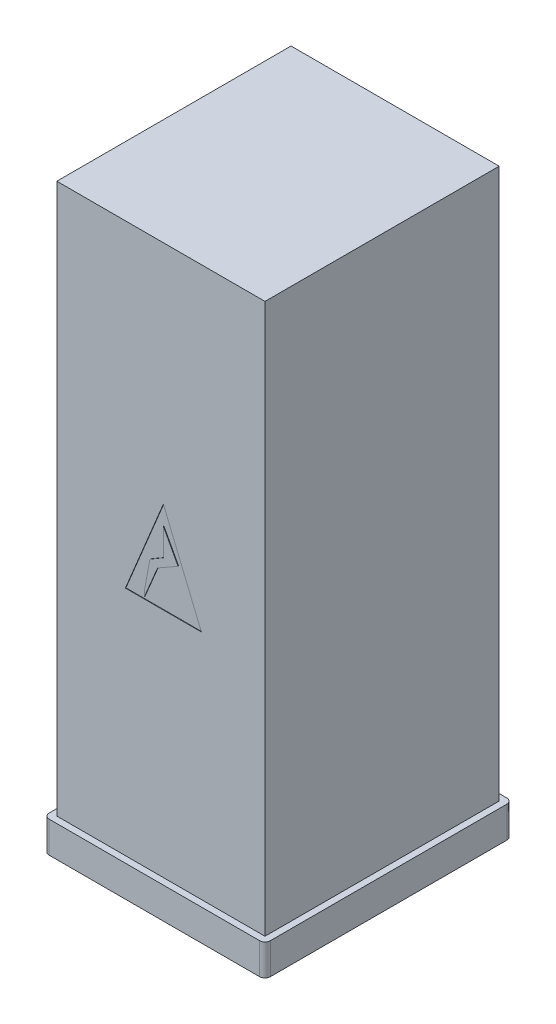
from build123d import *

# Parameters (mm, degrees)
CROQUIS1_W              = 800
CROQUIS1_H              = 900
SALIENTE_EXTRUIR1_DEPTH = 2113
VACIADO2_T              = -10
CROQUIS2_W              = 780
CROQUIS2_H              = 2093
SALIENTE_EXTRUIR2_DEPTH = 5
CORTAR_EXTRUIR1_DEPTH   = 2
SALIENTE_EXTRUIR3_DEPTH = 120


with BuildPart() as part:
    # Croquis1 → Saliente-Extruir1 (new body)
    with BuildSketch(Plane(origin=(0, 0, 0), x_dir=(1, 0, 0), z_dir=(0, 1, 0))):
        Rectangle(CROQUIS1_W, CROQUIS1_H)
    extrude(amount=SALIENTE_EXTRUIR1_DEPTH)

    # Vaciado2
    vaciado2_openings = [part.faces().sort_by_distance(p)[0] for p in [
        (0, 1056.5, 450),
    ]]
    offset(amount=VACIADO2_T, openings=vaciado2_openings, kind=Kind.INTERSECTION)

    # Croquis2 → Saliente-Extruir2 (add)
    with BuildSketch(Plane.XY.offset(450)):
        with Locations((0, 1056.5)):
            Rectangle(CROQUIS2_W, CROQUIS2_H)
    extrude(amount=-SALIENTE_EXTRUIR2_DEPTH)

    # Croquis3 → Cortar-Extruir1 (cut)
    with BuildSketch(Plane.XY.offset(450)):
        Polygon((-136.509991439, 890.520139483), (155.469712472, 890.520139483), (9.479860517, 1243.170950701), align=None)
        Polygon((-63.176808732, 920.19459615), (-42.169545822, 1034.041849102), (9.479860517, 1064.169920858), (9.479860517, 1169.411963853), (65.966344659, 1064.169920858), (-12.532301764, 1019.623730372), (-63.176808732, 898.913148296), align=None, mode=Mode.SUBTRACT)
    extrude(amount=-CORTAR_EXTRUIR1_DEPTH, mode=Mode.SUBTRACT)

    # Croquis4 → Saliente-Extruir3 (add)
    with BuildSketch(Plane.XZ):
        with BuildLine():
            Line((-404.35645152, 475), (404.35645152, 475))
            ThreePointArc((404.35645152, 475), (418.953644638, 468.953644638), (425, 454.35645152))
            Line((425, 454.35645152), (425, -454.35645152))
            ThreePointArc((425, -454.35645152), (418.953644638, -468.953644638), (404.35645152, -475))
            Line((404.35645152, -475), (-404.35645152, -475))
            ThreePointArc((-404.35645152, -475), (-418.953644638, -468.953644638), (-425, -454.35645152))
            Line((-425, -454.35645152), (-425, 454.35645152))
            ThreePointArc((-425, 454.35645152), (-418.953644638, 468.953644638), (-404.35645152, 475))
        make_face()
    extrude(amount=SALIENTE_EXTRUIR3_DEPTH)


solid = part.part
